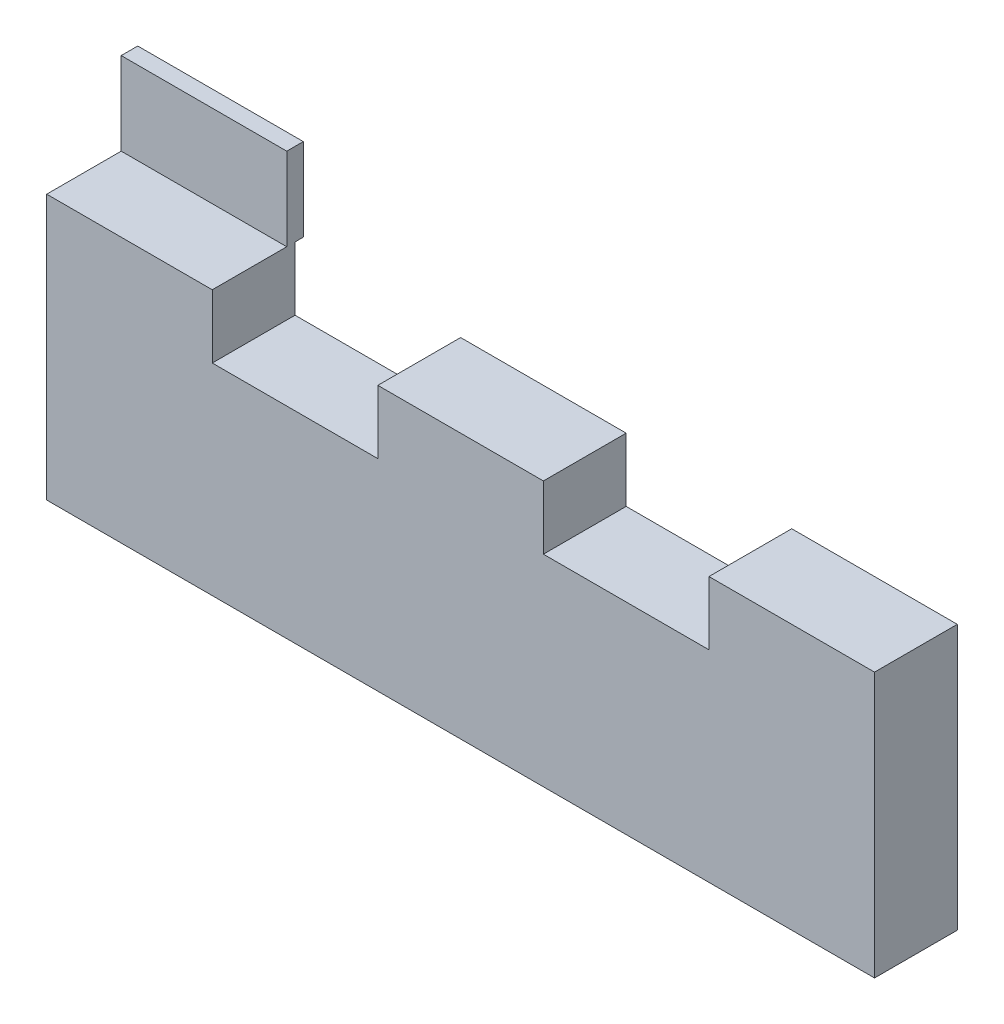
from build123d import *

# Parameters (mm, degrees)
BOSS_EXTRUDE2_DEPTH = 10
SKETCH2_W           = 20
SKETCH2_H           = 2
BOSS_EXTRUDE4_DEPTH = 10


with BuildPart() as part:
    # Sketch1 → Boss-Extrude2 (new body)
    with BuildSketch(Plane.XY):
        Polygon((0, 0), (0, 32), (20, 32), (20, 24.335329341), (40, 24.335329341), (40, 32), (60, 32), (60, 24.335329341), (80, 24.335329341), (80, 32), (100, 32), (100, 0), align=None)
    extrude(amount=BOSS_EXTRUDE2_DEPTH)

    # Sketch2 → Boss-Extrude4 (add)
    with BuildSketch(Plane(origin=(0, 32, 0), x_dir=(1, 0, 0), z_dir=(0, 1, 0))):
        with Locations((10, 0)):
            Rectangle(SKETCH2_W, SKETCH2_H)
    extrude(amount=BOSS_EXTRUDE4_DEPTH)


solid = part.part
